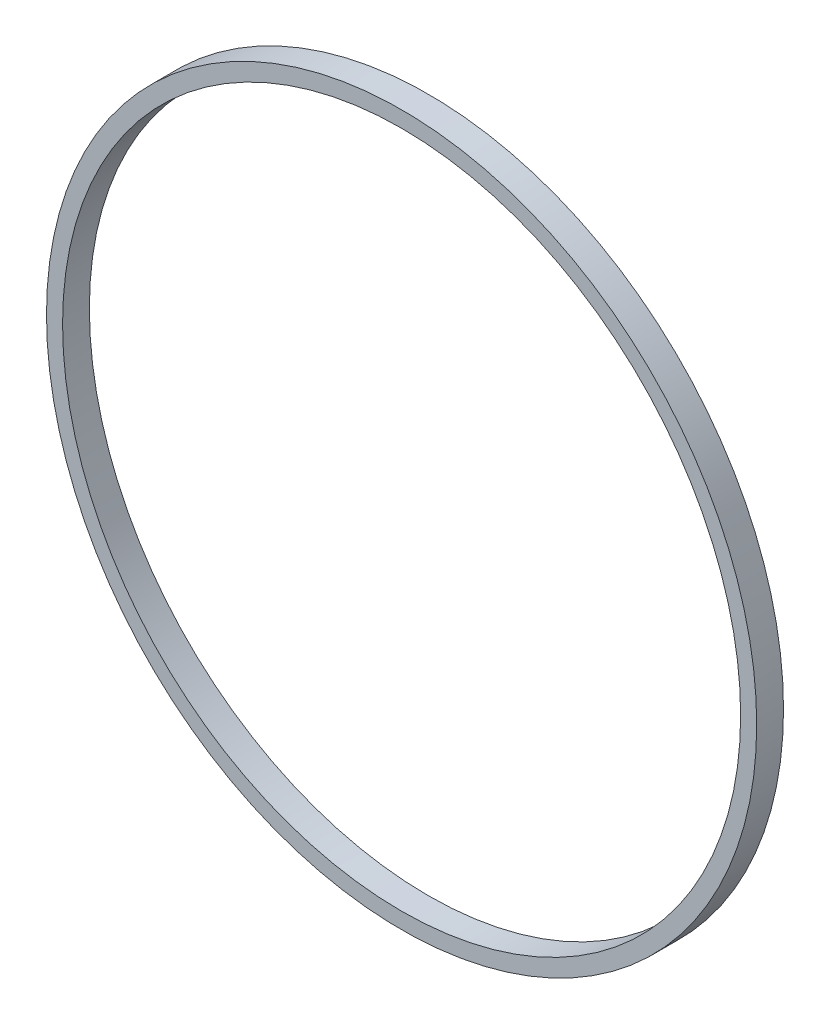
from build123d import *

# Parameters (mm, degrees)
CROQUIS1_R              = 66.25
CROQUIS1_R_2            = 63.25
SALIENTE_EXTRUIR1_DEPTH = 5


with BuildPart() as part:
    # Croquis1 → Saliente-Extruir1 (new body)
    with BuildSketch(Plane.XY):
        Circle(CROQUIS1_R)
        Circle(CROQUIS1_R_2, mode=Mode.SUBTRACT)
    extrude(amount=SALIENTE_EXTRUIR1_DEPTH)


solid = part.part
